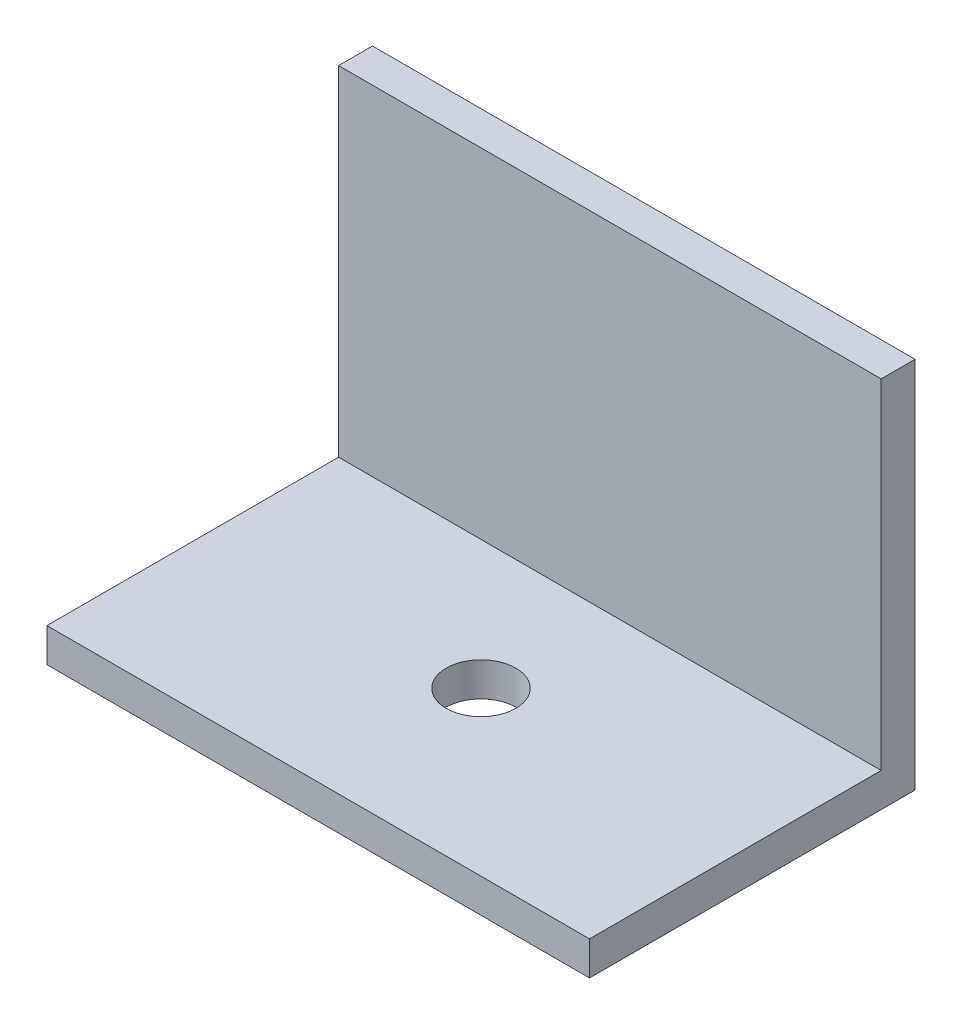
from build123d import *

# Parameters (mm, degrees)
SKETCH1_W           = 50.8
SKETCH1_H           = 30.48
BOSS_EXTRUDE1_DEPTH = 3.175
SKETCH2_W           = 50.8
SKETCH2_H           = 3.175
BOSS_EXTRUDE2_DEPTH = 31.75
SKETCH3_R           = 3.2639
CUT_EXTRUDE1_DEPTH  = 50.8


with BuildPart() as part:
    # Sketch1 → Boss-Extrude1 (new body)
    with BuildSketch(Plane(origin=(0, 0, 0), x_dir=(1, 0, 0), z_dir=(0, 1, 0))):
        Rectangle(SKETCH1_W, SKETCH1_H)
    extrude(amount=BOSS_EXTRUDE1_DEPTH)

    # Sketch2 → Boss-Extrude2 (add)
    with BuildSketch(Plane(origin=(0, 3.175, 0), x_dir=(1, 0, 0), z_dir=(0, 1, 0))):
        with Locations((0, 13.6525)):
            Rectangle(SKETCH2_W, SKETCH2_H)
    extrude(amount=BOSS_EXTRUDE2_DEPTH)

    # Sketch3 → Cut-Extrude1 (cut)
    with BuildSketch(Plane.XZ):
        Circle(SKETCH3_R)
    extrude(amount=-CUT_EXTRUDE1_DEPTH, mode=Mode.SUBTRACT)


solid = part.part
